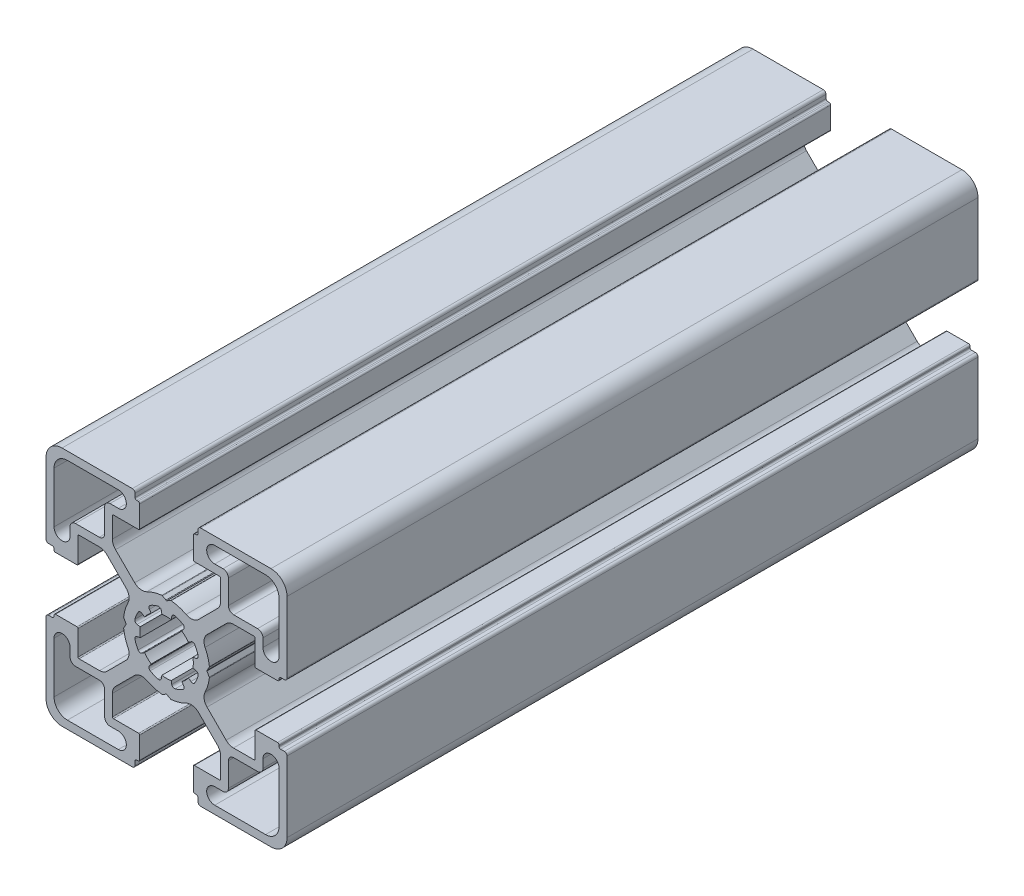
from build123d import *

# Parameters (mm, degrees)
BASE_EXTRUDE_DEPTH = 129


with BuildPart() as part:
    # Sketch1 → Base-Extrude (new body)
    with BuildSketch(Plane.XY):
        with BuildLine():
            Line((7.973976585, 0.792591518), (7.540060475, 0.046829556))
            ThreePointArc((7.540060475, 0.046829556), (7.534295984, 0.023675638), (7.531329941, 0))
            ThreePointArc((7.531329941, 0), (7.534295984, -0.023675638), (7.540060475, -0.046829556))
            Line((7.540060475, -0.046829556), (7.973976585, -0.792591518))
            ThreePointArc((7.973976585, -0.792591518), (7.996666421, -0.851255641), (8.000014047, -0.914065683))
            ThreePointArc((8.000014047, -0.914065683), (7.719730741, -2.298395946), (7.20036345, -3.611859543))
            ThreePointArc((7.20036345, -3.611859543), (7.018857217, -4.793954471), (7.563483933, -5.85869607))
            Line((7.563483933, -5.85869607), (11.129779889, -9.424988026))
            ThreePointArc((11.129779889, -9.424988026), (11.760624613, -9.84650461), (12.504756513, -9.99452154))
            Line((12.504756513, -9.99452154), (16.316902451, -9.99452154))
            ThreePointArc((16.316902451, -9.99452154), (16.458324055, -9.935942793), (16.516902802, -9.794521189))
            Line((16.516902802, -9.794521189), (16.516902802, -5.200014226))
            ThreePointArc((16.516902802, -5.200014226), (16.575481548, -5.058592621), (16.716903152, -5.000013875))
            Line((16.716903152, -5.000013875), (20.719599904, -5.000013875))
            ThreePointArc((20.719599904, -5.000013875), (20.931731427, -5.087881629), (21.01959918, -5.300013151))
            Line((21.01959918, -5.300013151), (21.01959918, -5.500004099))
            ThreePointArc((21.01959918, -5.500004099), (21.10746708, -5.712135974), (21.319598956, -5.800003874))
            Line((21.319598956, -5.800003874), (21.999979514, -5.800003874))
            ThreePointArc((21.999979514, -5.800003874), (22.35353264, -5.946450374), (22.49997914, -6.300003501))
            Line((22.49997914, -6.300003501), (22.49997914, -19.500016116))
            ThreePointArc((22.49997914, -19.500016116), (21.62130014, -21.621334875), (19.499981381, -22.500013875))
            Line((19.499981381, -22.500013875), (6.375709012, -22.500013875))
            ThreePointArc((6.375709012, -22.500013875), (6.022155886, -22.353567375), (5.875709386, -22.000014249))
            Line((5.875709386, -22.000014249), (5.875709386, -21.30001315))
            ThreePointArc((5.875709386, -21.30001315), (5.787841632, -21.087881628), (5.57571011, -21.000013874))
            Line((5.57571011, -21.000013874), (5.299998776, -21.000013874))
            ThreePointArc((5.299998776, -21.000013874), (5.087867607, -20.912146267), (5, -20.700015099))
            Line((5, -20.700015099), (5, -16.666812433))
            ThreePointArc((5, -16.666812433), (5.058578893, -16.525390475), (5.200000851, -16.466811582))
            Line((5.200000851, -16.466811582), (9.905385218, -16.466811582))
            ThreePointArc((9.905385218, -16.466811582), (10.046806822, -16.408232835), (10.105385569, -16.266811231))
            Line((10.105385569, -16.266811231), (10.105385569, -12.471582956))
            ThreePointArc((10.105385569, -12.471582956), (9.953144588, -11.706215861), (9.519598955, -11.057368968))
            Line((9.519598955, -11.057368968), (5.944897989, -7.482668002))
            ThreePointArc((5.944897989, -7.482668002), (4.854601835, -6.967833724), (3.666499237, -7.173289937))
            ThreePointArc((3.666499237, -7.173289937), (2.309136684, -7.713848333), (0.876396038, -8.000013875))
            ThreePointArc((0.876396038, -8.000013875), (0.81356491, -7.997088573), (0.754749577, -7.974793627))
            Line((0.754749577, -7.974793627), (0.11262846, -7.606936933))
            ThreePointArc((0.11262846, -7.606936933), (0.062963903, -7.559088739), (0, -7.530953975))
            ThreePointArc((0, -7.530953975), (-0.062963903, -7.559088739), (-0.11262846, -7.606936933))
            Line((-0.11262846, -7.606936933), (-0.754749577, -7.974793627))
            ThreePointArc((-0.754749577, -7.974793627), (-0.81356491, -7.997088573), (-0.876396038, -8.000013875))
            ThreePointArc((-0.876396038, -8.000013875), (-2.309136684, -7.713848333), (-3.666499237, -7.173289937))
            ThreePointArc((-3.666499237, -7.173289937), (-4.854601835, -6.967833724), (-5.944897989, -7.482668002))
            Line((-5.944897989, -7.482668002), (-9.519598955, -11.057368968))
            ThreePointArc((-9.519598955, -11.057368968), (-9.953144588, -11.706215861), (-10.105385569, -12.471582956))
            Line((-10.105385569, -12.471582956), (-10.105385569, -16.266811231))
            ThreePointArc((-10.105385569, -16.266811231), (-10.046806822, -16.408232835), (-9.905385218, -16.466811582))
            Line((-9.905385218, -16.466811582), (-5.200000851, -16.466811582))
            ThreePointArc((-5.200000851, -16.466811582), (-5.058578893, -16.525390475), (-5, -16.666812433))
            Line((-5, -16.666812433), (-5, -20.700015099))
            ThreePointArc((-5, -20.700015099), (-5.087867607, -20.912146267), (-5.299998776, -21.000013874))
            Line((-5.299998776, -21.000013874), (-5.57571011, -21.000013874))
            ThreePointArc((-5.57571011, -21.000013874), (-5.787841632, -21.087881628), (-5.875709386, -21.30001315))
            Line((-5.875709386, -21.30001315), (-5.875709386, -22.000014249))
            ThreePointArc((-5.875709386, -22.000014249), (-6.022155886, -22.353567375), (-6.375709012, -22.500013875))
            Line((-6.375709012, -22.500013875), (-19.499981381, -22.500013875))
            ThreePointArc((-19.499981381, -22.500013875), (-21.62130014, -21.621334875), (-22.49997914, -19.500016116))
            Line((-22.49997914, -19.500016116), (-22.49997914, -6.300003501))
            ThreePointArc((-22.49997914, -6.300003501), (-22.35353264, -5.946450374), (-21.999979514, -5.800003874))
            Line((-21.999979514, -5.800003874), (-21.319598956, -5.800003874))
            ThreePointArc((-21.319598956, -5.800003874), (-21.10746708, -5.712135974), (-21.01959918, -5.500004099))
            Line((-21.01959918, -5.500004099), (-21.01959918, -5.300013151))
            ThreePointArc((-21.01959918, -5.300013151), (-20.931731427, -5.087881629), (-20.719599904, -5.000013875))
            Line((-20.719599904, -5.000013875), (-16.716903152, -5.000013875))
            ThreePointArc((-16.716903152, -5.000013875), (-16.575481548, -5.058592621), (-16.516902802, -5.200014226))
            Line((-16.516902802, -5.200014226), (-16.516902802, -9.794521189))
            ThreePointArc((-16.516902802, -9.794521189), (-16.458324055, -9.935942793), (-16.316902451, -9.99452154))
            Line((-16.316902451, -9.99452154), (-12.504756513, -9.99452154))
            ThreePointArc((-12.504756513, -9.99452154), (-11.760624613, -9.84650461), (-11.129779889, -9.424988026))
            Line((-11.129779889, -9.424988026), (-7.563483933, -5.85869607))
            ThreePointArc((-7.563483933, -5.85869607), (-7.018857217, -4.793954471), (-7.20036345, -3.611859543))
            ThreePointArc((-7.20036345, -3.611859543), (-7.719730741, -2.298395946), (-8.000014047, -0.914065683))
            ThreePointArc((-8.000014047, -0.914065683), (-7.996666421, -0.851255641), (-7.973976585, -0.792591518))
            Line((-7.973976585, -0.792591518), (-7.540060475, -0.046829556))
            ThreePointArc((-7.540060475, -0.046829556), (-7.534295984, -0.023675638), (-7.531329941, 0))
            ThreePointArc((-7.531329941, 0), (-7.534295984, 0.023675638), (-7.540060475, 0.046829556))
            Line((-7.540060475, 0.046829556), (-7.973976585, 0.792591518))
            ThreePointArc((-7.973976585, 0.792591518), (-7.996666421, 0.851255641), (-8.000014047, 0.914065683))
            ThreePointArc((-8.000014047, 0.914065683), (-7.719730741, 2.298395946), (-7.20036345, 3.611859543))
            ThreePointArc((-7.20036345, 3.611859543), (-7.018857217, 4.793954471), (-7.563483933, 5.85869607))
            Line((-7.563483933, 5.85869607), (-11.129779889, 9.424988026))
            ThreePointArc((-11.129779889, 9.424988026), (-11.760624613, 9.84650461), (-12.504756513, 9.99452154))
            Line((-12.504756513, 9.99452154), (-16.316902451, 9.99452154))
            ThreePointArc((-16.316902451, 9.99452154), (-16.458324055, 9.935942793), (-16.516902802, 9.794521189))
            Line((-16.516902802, 9.794521189), (-16.516902802, 5.200014226))
            ThreePointArc((-16.516902802, 5.200014226), (-16.575481548, 5.058592621), (-16.716903152, 5.000013875))
            Line((-16.716903152, 5.000013875), (-20.719599904, 5.000013875))
            ThreePointArc((-20.719599904, 5.000013875), (-20.931731427, 5.087881629), (-21.01959918, 5.300013151))
            Line((-21.01959918, 5.300013151), (-21.01959918, 5.500004099))
            ThreePointArc((-21.01959918, 5.500004099), (-21.10746708, 5.712135974), (-21.319598956, 5.800003874))
            Line((-21.319598956, 5.800003874), (-21.999979514, 5.800003874))
            ThreePointArc((-21.999979514, 5.800003874), (-22.35353264, 5.946450374), (-22.49997914, 6.300003501))
            Line((-22.49997914, 6.300003501), (-22.49997914, 19.500016116))
            ThreePointArc((-22.49997914, 19.500016116), (-21.62130014, 21.621334875), (-19.499981381, 22.500013875))
            Line((-19.499981381, 22.500013875), (-6.375709012, 22.500013875))
            ThreePointArc((-6.375709012, 22.500013875), (-6.022155886, 22.353567375), (-5.875709386, 22.000014249))
            Line((-5.875709386, 22.000014249), (-5.875709386, 21.30001315))
            ThreePointArc((-5.875709386, 21.30001315), (-5.787841632, 21.087881628), (-5.57571011, 21.000013874))
            Line((-5.57571011, 21.000013874), (-5.299998776, 21.000013874))
            ThreePointArc((-5.299998776, 21.000013874), (-5.087867607, 20.912146267), (-5, 20.700015099))
            Line((-5, 20.700015099), (-5, 16.666812433))
            ThreePointArc((-5, 16.666812433), (-5.058578893, 16.525390475), (-5.200000851, 16.466811582))
            Line((-5.200000851, 16.466811582), (-9.905385218, 16.466811582))
            ThreePointArc((-9.905385218, 16.466811582), (-10.046806822, 16.408232835), (-10.105385569, 16.266811231))
            Line((-10.105385569, 16.266811231), (-10.105385569, 12.471582956))
            ThreePointArc((-10.105385569, 12.471582956), (-9.953144588, 11.706215861), (-9.519598955, 11.057368968))
            Line((-9.519598955, 11.057368968), (-5.944897989, 7.482668002))
            ThreePointArc((-5.944897989, 7.482668002), (-4.854601835, 6.967833724), (-3.666499237, 7.173289937))
            ThreePointArc((-3.666499237, 7.173289937), (-2.309136684, 7.713848333), (-0.876396038, 8.000013875))
            ThreePointArc((-0.876396038, 8.000013875), (-0.81356491, 7.997088573), (-0.754749577, 7.974793627))
            Line((-0.754749577, 7.974793627), (-0.11262846, 7.606936933))
            ThreePointArc((-0.11262846, 7.606936933), (-0.062963903, 7.559088739), (0, 7.530953975))
            ThreePointArc((0, 7.530953975), (0.062963903, 7.559088739), (0.11262846, 7.606936933))
            Line((0.11262846, 7.606936933), (0.754749577, 7.974793627))
            ThreePointArc((0.754749577, 7.974793627), (0.81356491, 7.997088573), (0.876396038, 8.000013875))
            ThreePointArc((0.876396038, 8.000013875), (2.309136684, 7.713848333), (3.666499237, 7.173289937))
            ThreePointArc((3.666499237, 7.173289937), (4.854601835, 6.967833724), (5.944897989, 7.482668002))
            Line((5.944897989, 7.482668002), (9.519598955, 11.057368968))
            ThreePointArc((9.519598955, 11.057368968), (9.953144588, 11.706215861), (10.105385569, 12.471582956))
            Line((10.105385569, 12.471582956), (10.105385569, 16.266811231))
            ThreePointArc((10.105385569, 16.266811231), (10.046806822, 16.408232835), (9.905385218, 16.466811582))
            Line((9.905385218, 16.466811582), (5.200000851, 16.466811582))
            ThreePointArc((5.200000851, 16.466811582), (5.058578893, 16.525390475), (5, 16.666812433))
            Line((5, 16.666812433), (5, 20.700015099))
            ThreePointArc((5, 20.700015099), (5.087867607, 20.912146267), (5.299998776, 21.000013874))
            Line((5.299998776, 21.000013874), (5.57571011, 21.000013874))
            ThreePointArc((5.57571011, 21.000013874), (5.787841632, 21.087881628), (5.875709386, 21.30001315))
            Line((5.875709386, 21.30001315), (5.875709386, 22.000014249))
            ThreePointArc((5.875709386, 22.000014249), (6.022155886, 22.353567375), (6.375709012, 22.500013875))
            Line((6.375709012, 22.500013875), (19.499981381, 22.500013875))
            ThreePointArc((19.499981381, 22.500013875), (21.62130014, 21.621334875), (22.49997914, 19.500016116))
            Line((22.49997914, 19.500016116), (22.49997914, 6.300003501))
            ThreePointArc((22.49997914, 6.300003501), (22.35353264, 5.946450374), (21.999979514, 5.800003874))
            Line((21.999979514, 5.800003874), (21.319598956, 5.800003874))
            ThreePointArc((21.319598956, 5.800003874), (21.10746708, 5.712135974), (21.01959918, 5.500004099))
            Line((21.01959918, 5.500004099), (21.01959918, 5.300013151))
            ThreePointArc((21.01959918, 5.300013151), (20.931731427, 5.087881629), (20.719599904, 5.000013875))
            Line((20.719599904, 5.000013875), (16.716903152, 5.000013875))
            ThreePointArc((16.716903152, 5.000013875), (16.575481548, 5.058592621), (16.516902802, 5.200014226))
            Line((16.516902802, 5.200014226), (16.516902802, 9.794521189))
            ThreePointArc((16.516902802, 9.794521189), (16.458324055, 9.935942793), (16.316902451, 9.99452154))
            Line((16.316902451, 9.99452154), (12.504756513, 9.99452154))
            ThreePointArc((12.504756513, 9.99452154), (11.760624613, 9.84650461), (11.129779889, 9.424988026))
            Line((11.129779889, 9.424988026), (7.563483933, 5.85869607))
            ThreePointArc((7.563483933, 5.85869607), (7.018857217, 4.793954471), (7.20036345, 3.611859543))
            ThreePointArc((7.20036345, 3.611859543), (7.719730741, 2.298395946), (8.000014047, 0.914065683))
            ThreePointArc((8.000014047, 0.914065683), (7.996666421, 0.851255641), (7.973976585, 0.792591518))
        make_face()
        with BuildLine():
            Line((10.549978885, 18.000013874), (8.999979138, 18.000013874))
            ThreePointArc((8.999979138, 18.000013874), (7.499979138, 19.500013874), (8.999979138, 21.000013874))
            Line((8.999979138, 21.000013874), (18.499981006, 21.000013874))
            ThreePointArc((18.499981006, 21.000013874), (20.267746638, 20.267781374), (20.999979138, 18.500015742))
            Line((20.999979138, 18.500015742), (20.999979138, 9.000204874))
            ThreePointArc((20.999979138, 9.000204874), (19.499979138, 7.500204874), (17.999979138, 9.000204874))
            Line((17.999979138, 9.000204874), (17.999979138, 10.550013621))
            ThreePointArc((17.999979138, 10.550013621), (17.707086138, 11.257119874), (16.999979885, 11.550012874))
            Line((16.999979885, 11.550012874), (12.549977391, 11.550012874))
            ThreePointArc((12.549977391, 11.550012874), (11.842871138, 11.842905874), (11.549978138, 12.550012127))
            Line((11.549978138, 12.550012127), (11.549978138, 17.000014621))
            ThreePointArc((11.549978138, 17.000014621), (11.257085138, 17.707120874), (10.549978885, 18.000013874))
        make_face(mode=Mode.SUBTRACT)
        with BuildLine():
            Line((-0.867388737, 4.924188946), (-0.96752168, 5.481112935))
            ThreePointArc((-0.96752168, 5.481112935), (-1.187855719, 5.829589164), (-1.595071417, 5.894072848))
            ThreePointArc((-1.595071417, 5.894072848), (-2.338895973, 5.643477696), (-3.04438497, 5.299445466))
            ThreePointArc((-3.04438497, 5.299445466), (-3.284615367, 4.964275075), (-3.191311906, 4.562598216))
            Line((-3.191311906, 4.562598216), (-2.864000421, 4.09847552))
            ThreePointArc((-2.864000421, 4.09847552), (-3.53013295, 3.540926624), (-4.08971289, 2.876499344))
            Line((-4.08971289, 2.876499344), (-4.566777651, 3.208162503))
            ThreePointArc((-4.566777651, 3.208162503), (-4.968960845, 3.298770682), (-5.302497889, 3.056460542))
            ThreePointArc((-5.302497889, 3.056460542), (-5.651259984, 2.353310881), (-5.906847665, 1.611199444))
            ThreePointArc((-5.906847665, 1.611199444), (-5.839752063, 1.204293023), (-5.489730697, 0.98621116))
            Line((-5.489730697, 0.98621116), (-4.920545766, 0.887822825))
            ThreePointArc((-4.920545766, 0.887822825), (-4.980096828, 0.445685524), (-5, 0))
            ThreePointArc((-5, 0), (-4.980096828, -0.445685524), (-4.920545766, -0.887822825))
            Line((-4.920545766, -0.887822825), (-5.489730697, -0.98621116))
            ThreePointArc((-5.489730697, -0.98621116), (-5.839752063, -1.204293023), (-5.906847665, -1.611199444))
            ThreePointArc((-5.906847665, -1.611199444), (-5.651259984, -2.353310881), (-5.302497889, -3.056460542))
            ThreePointArc((-5.302497889, -3.056460542), (-4.968960845, -3.298770682), (-4.566777651, -3.208162503))
            Line((-4.566777651, -3.208162503), (-4.08971289, -2.876499344))
            ThreePointArc((-4.08971289, -2.876499344), (-3.53013295, -3.540926624), (-2.864000421, -4.09847552))
            Line((-2.864000421, -4.09847552), (-3.191311906, -4.562598216))
            ThreePointArc((-3.191311906, -4.562598216), (-3.284615367, -4.964275075), (-3.04438497, -5.299445466))
            ThreePointArc((-3.04438497, -5.299445466), (-2.338895973, -5.643477696), (-1.595071417, -5.894072848))
            ThreePointArc((-1.595071417, -5.894072848), (-1.187855719, -5.829589164), (-0.96752168, -5.481112935))
            Line((-0.96752168, -5.481112935), (-0.867388737, -4.924188946))
            ThreePointArc((-0.867388737, -4.924188946), (0, -5), (0.867388737, -4.924188946))
            Line((0.867388737, -4.924188946), (0.96752168, -5.481112935))
            ThreePointArc((0.96752168, -5.481112935), (1.187855719, -5.829589164), (1.595071417, -5.894072848))
            ThreePointArc((1.595071417, -5.894072848), (2.338895973, -5.643477696), (3.04438497, -5.299445466))
            ThreePointArc((3.04438497, -5.299445466), (3.284615367, -4.964275075), (3.191311906, -4.562598216))
            Line((3.191311906, -4.562598216), (2.864000421, -4.09847552))
            ThreePointArc((2.864000421, -4.09847552), (3.53013295, -3.540926624), (4.08971289, -2.876499344))
            Line((4.08971289, -2.876499344), (4.566777651, -3.208162503))
            ThreePointArc((4.566777651, -3.208162503), (4.968960845, -3.298770682), (5.302497889, -3.056460542))
            ThreePointArc((5.302497889, -3.056460542), (5.651259984, -2.353310881), (5.906847665, -1.611199444))
            ThreePointArc((5.906847665, -1.611199444), (5.839752063, -1.204293023), (5.489730697, -0.98621116))
            Line((5.489730697, -0.98621116), (4.920545766, -0.887822825))
            ThreePointArc((4.920545766, -0.887822825), (4.980096828, -0.445685524), (5, 0))
            ThreePointArc((5, 0), (4.980096828, 0.445685524), (4.920545766, 0.887822825))
            Line((4.920545766, 0.887822825), (5.489730697, 0.98621116))
            ThreePointArc((5.489730697, 0.98621116), (5.839752063, 1.204293023), (5.906847665, 1.611199444))
            ThreePointArc((5.906847665, 1.611199444), (5.651259984, 2.353310881), (5.302497889, 3.056460542))
            ThreePointArc((5.302497889, 3.056460542), (4.968960845, 3.298770682), (4.566777651, 3.208162503))
            Line((4.566777651, 3.208162503), (4.08971289, 2.876499344))
            ThreePointArc((4.08971289, 2.876499344), (3.53013295, 3.540926624), (2.864000421, 4.09847552))
            Line((2.864000421, 4.09847552), (3.191311906, 4.562598216))
            ThreePointArc((3.191311906, 4.562598216), (3.284615367, 4.964275075), (3.04438497, 5.299445466))
            ThreePointArc((3.04438497, 5.299445466), (2.338895973, 5.643477696), (1.595071417, 5.894072848))
            ThreePointArc((1.595071417, 5.894072848), (1.187855719, 5.829589164), (0.96752168, 5.481112935))
            Line((0.96752168, 5.481112935), (0.867388737, 4.924188946))
            ThreePointArc((0.867388737, 4.924188946), (0, 5), (-0.867388737, 4.924188946))
        make_face(mode=Mode.SUBTRACT)
        with BuildLine():
            Line((-10.549978885, -18.000013874), (-8.999979138, -18.000013874))
            ThreePointArc((-8.999979138, -18.000013874), (-7.499979138, -19.500013874), (-8.999979138, -21.000013874))
            Line((-8.999979138, -21.000013874), (-18.499981006, -21.000013874))
            ThreePointArc((-18.499981006, -21.000013874), (-20.267746638, -20.267781374), (-20.999979138, -18.500015742))
            Line((-20.999979138, -18.500015742), (-20.999979138, -9.000204874))
            ThreePointArc((-20.999979138, -9.000204874), (-19.499979138, -7.500204874), (-17.999979138, -9.000204874))
            Line((-17.999979138, -9.000204874), (-17.999979138, -10.550013621))
            ThreePointArc((-17.999979138, -10.550013621), (-17.707086138, -11.257119874), (-16.999979885, -11.550012874))
            Line((-16.999979885, -11.550012874), (-12.549977391, -11.550012874))
            ThreePointArc((-12.549977391, -11.550012874), (-11.842871138, -11.842905874), (-11.549978138, -12.550012127))
            Line((-11.549978138, -12.550012127), (-11.549978138, -17.000014621))
            ThreePointArc((-11.549978138, -17.000014621), (-11.257085138, -17.707120874), (-10.549978885, -18.000013874))
        make_face(mode=Mode.SUBTRACT)
        with BuildLine():
            Line((-11.549978138, 12.550012127), (-11.549978138, 17.000014621))
            ThreePointArc((-11.549978138, 17.000014621), (-11.257085138, 17.707120874), (-10.549978885, 18.000013874))
            Line((-10.549978885, 18.000013874), (-8.999979138, 18.000013874))
            ThreePointArc((-8.999979138, 18.000013874), (-7.499979138, 19.500013874), (-8.999979138, 21.000013874))
            Line((-8.999979138, 21.000013874), (-18.499981006, 21.000013874))
            ThreePointArc((-18.499981006, 21.000013874), (-20.267746638, 20.267781374), (-20.999979138, 18.500015742))
            Line((-20.999979138, 18.500015742), (-20.999979138, 9.000204874))
            ThreePointArc((-20.999979138, 9.000204874), (-19.499979138, 7.500204874), (-17.999979138, 9.000204874))
            Line((-17.999979138, 9.000204874), (-17.999979138, 10.550013621))
            ThreePointArc((-17.999979138, 10.550013621), (-17.707086138, 11.257119874), (-16.999979885, 11.550012874))
            Line((-16.999979885, 11.550012874), (-12.549977391, 11.550012874))
            ThreePointArc((-12.549977391, 11.550012874), (-11.842871138, 11.842905874), (-11.549978138, 12.550012127))
        make_face(mode=Mode.SUBTRACT)
        with BuildLine():
            Line((11.549978138, -12.550012127), (11.549978138, -17.000014621))
            ThreePointArc((11.549978138, -17.000014621), (11.257085138, -17.707120874), (10.549978885, -18.000013874))
            Line((10.549978885, -18.000013874), (8.999979138, -18.000013874))
            ThreePointArc((8.999979138, -18.000013874), (7.499979138, -19.500013874), (8.999979138, -21.000013874))
            Line((8.999979138, -21.000013874), (18.499981006, -21.000013874))
            ThreePointArc((18.499981006, -21.000013874), (20.267746638, -20.267781374), (20.999979138, -18.500015742))
            Line((20.999979138, -18.500015742), (20.999979138, -9.000204874))
            ThreePointArc((20.999979138, -9.000204874), (19.499979138, -7.500204874), (17.999979138, -9.000204874))
            Line((17.999979138, -9.000204874), (17.999979138, -10.550013621))
            ThreePointArc((17.999979138, -10.550013621), (17.707086138, -11.257119874), (16.999979885, -11.550012874))
            Line((16.999979885, -11.550012874), (12.549977391, -11.550012874))
            ThreePointArc((12.549977391, -11.550012874), (11.842871138, -11.842905874), (11.549978138, -12.550012127))
        make_face(mode=Mode.SUBTRACT)
    extrude(amount=-BASE_EXTRUDE_DEPTH)


solid = part.part
